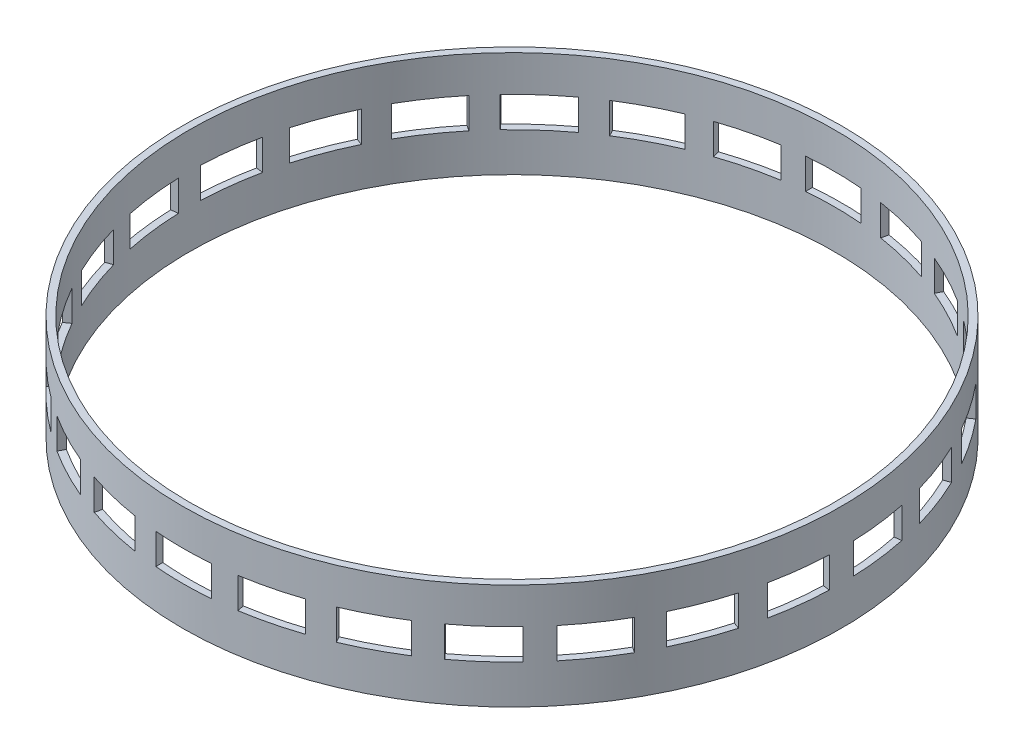
from build123d import *

# Parameters (mm, degrees)
SKETCH1_R           = 118.5
SKETCH1_R_2         = 116
BOSS_EXTRUDE1_DEPTH = 38
SKETCH2_W           = 20
SKETCH2_H           = 11
CUT_EXTRUDE1_DEPTH  = 119.5
CIRPATTERN1_COUNT   = 13


with BuildPart() as part:
    # Sketch1 → Boss-Extrude1 (new body)
    with BuildSketch(Plane(origin=(0, 0, 0), x_dir=(1, 0, 0), z_dir=(0, 1, 0))):
        Circle(SKETCH1_R)
        Circle(SKETCH1_R_2, mode=Mode.SUBTRACT)
    extrude(amount=BOSS_EXTRUDE1_DEPTH)

    # Sketch2 → Cut-Extrude1 (cut, symmetric)
    with BuildSketch(Plane.XY):
        with Locations((0, 19.5)):
            Rectangle(SKETCH2_W, SKETCH2_H)
    cut_extrude1 = extrude(amount=CUT_EXTRUDE1_DEPTH, both=True, mode=Mode.SUBTRACT)

    # CirPattern1: Cut-Extrude1 ×13 about axis
    cirpattern1_axis = Axis((0, 0, 0), (0, 1, 0))
    for i in range(1, CIRPATTERN1_COUNT):
        add(cut_extrude1.rotate(cirpattern1_axis, i * 360 / CIRPATTERN1_COUNT), mode=Mode.SUBTRACT)


solid = part.part
